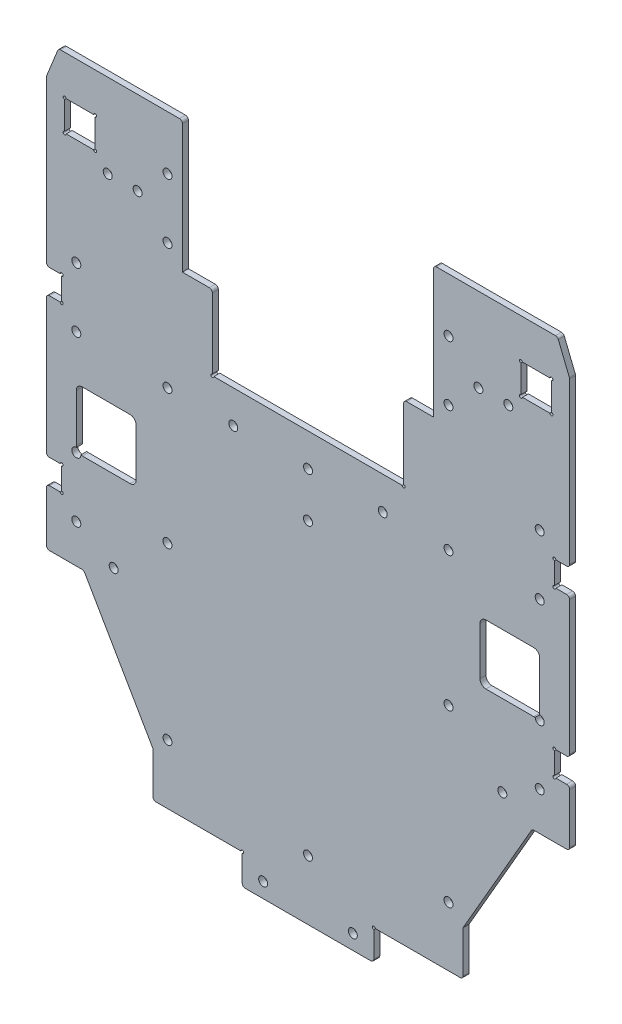
from build123d import *

# Parameters (mm, degrees)
SKETCH_1_R          = 1.5
SKETCH_1_W          = 10.2
SKETCH_1_H          = 10.2
EXTRUDE_3_DEPTH     = 2
SKETCH_3_R          = 1.5
SKETCH_3_W          = 5.1
SKETCH_3_H          = 8.2
CUT_EXTRUDE_2_DEPTH = 3
SKETCH_4_W          = 10
SKETCH_4_H          = 25
EXTRUDE_4_DEPTH     = 2
SKETCH_2_R          = 0.5
CUT_EXTRUDE_1_DEPTH = 3
FILLET_1_R          = 1
CUT_EXTRUDE_3_DEPTH = 10
SKETCH_6_R          = 1.5
CUT_EXTRUDE_4_DEPTH = 10


with BuildPart() as part:
    # 草图1 → 凸台-拉伸3 (new body)
    with BuildSketch(Plane.XY):
        Polygon((-87.5, 69), (-87.5, -77.9), (-74.994010768, -77.9), (-51.9, -117.9), (-51.9, -132.9), (-22, -132.9), (-22, -143), (22, -143), (22, -132.9), (51.9, -132.9), (51.9, -117.9), (74.994010768, -77.9), (87.5, -77.9), (87.5, 69), (42, 69), (42, 0), (-42, 0), (-42, 69), align=None)
        with Locations((-25, -11)):
            Circle(SKETCH_1_R, mode=Mode.SUBTRACT)
        with Locations((0, -26)):
            Circle(SKETCH_1_R, mode=Mode.SUBTRACT)
        with Locations((-47, -11)):
            Circle(SKETCH_1_R, mode=Mode.SUBTRACT)
        with Locations((-15, -138)):
            Circle(SKETCH_1_R, mode=Mode.SUBTRACT)
        with Locations((0, -123)):
            Circle(SKETCH_1_R, mode=Mode.SUBTRACT)
        with Locations((47, -11)):
            Circle(SKETCH_1_R, mode=Mode.SUBTRACT)
        with Locations((25, -11)):
            Circle(SKETCH_1_R, mode=Mode.SUBTRACT)
        with Locations((15, -138)):
            Circle(SKETCH_1_R, mode=Mode.SUBTRACT)
        with Locations((0, -11)):
            Circle(SKETCH_1_R, mode=Mode.SUBTRACT)
        with Locations((-47, 51)):
            Circle(SKETCH_1_R, mode=Mode.SUBTRACT)
        with Locations((47, 51)):
            Circle(SKETCH_1_R, mode=Mode.SUBTRACT)
        with Locations((-47, -113)):
            Circle(SKETCH_1_R, mode=Mode.SUBTRACT)
        with Locations((-47, -56)):
            Circle(SKETCH_1_R, mode=Mode.SUBTRACT)
        with Locations((47, -56)):
            Circle(SKETCH_1_R, mode=Mode.SUBTRACT)
        with Locations((47, -113)):
            Circle(SKETCH_1_R, mode=Mode.SUBTRACT)
        with Locations((-47, 31)):
            Circle(SKETCH_1_R, mode=Mode.SUBTRACT)
        with Locations((-67, 41)):
            Circle(SKETCH_1_R, mode=Mode.SUBTRACT)
        with Locations((-57, 41)):
            Circle(SKETCH_1_R, mode=Mode.SUBTRACT)
        with Locations((57, 41)):
            Circle(SKETCH_1_R, mode=Mode.SUBTRACT)
        with Locations((67, 41)):
            Circle(SKETCH_1_R, mode=Mode.SUBTRACT)
        with Locations((47, 31)):
            Circle(SKETCH_1_R, mode=Mode.SUBTRACT)
        with Locations((76.3, 50.7)):
            Rectangle(SKETCH_1_W, SKETCH_1_H, mode=Mode.SUBTRACT)
        with Locations((-76.3, 50.7)):
            Rectangle(SKETCH_1_W, SKETCH_1_H, mode=Mode.SUBTRACT)
    extrude(amount=EXTRUDE_3_DEPTH)

    # 草图3 → 切除-拉伸2 (cut, through all)
    with BuildSketch(Plane.XY.offset(2)):
        with Locations((77.5, 10)):
            Circle(SKETCH_3_R)
        with Locations((77.5, -10)):
            Circle(SKETCH_3_R)
        with Locations((77.5, -45)):
            Circle(SKETCH_3_R)
        with Locations((77.5, -65)):
            Circle(SKETCH_3_R)
        with Locations((-77.5, -45)):
            Circle(SKETCH_3_R)
        with Locations((-77.5, -65)):
            Circle(SKETCH_3_R)
        with Locations((-77.5, -10)):
            Circle(SKETCH_3_R)
        with Locations((-77.5, 10)):
            Circle(SKETCH_3_R)
        with Locations((84.95, 0)):
            Rectangle(SKETCH_3_W, SKETCH_3_H)
        with Locations((-84.95, 0)):
            Rectangle(SKETCH_3_W, SKETCH_3_H)
        with Locations((-84.95, -55)):
            Rectangle(SKETCH_3_W, SKETCH_3_H)
        with Locations((84.95, -55)):
            Rectangle(SKETCH_3_W, SKETCH_3_H)
        Polygon((83.459737742, 69), (87.5, 59), (87.5, 69), align=None)
        Polygon((-87.5, 59), (-87.5, 69), (-83.459737742, 69), align=None)
    extrude(amount=-CUT_EXTRUDE_2_DEPTH, mode=Mode.SUBTRACT)

    # 草图4 → 凸台-拉伸4 (add)
    with BuildSketch(Plane(origin=(0, 0, 0), x_dir=(-1, 0, 0), z_dir=(0, 0, -1))):
        with Locations((-37, 12.5)):
            Rectangle(SKETCH_4_W, SKETCH_4_H)
        with Locations((37, 12.5)):
            Rectangle(SKETCH_4_W, SKETCH_4_H)
    extrude(amount=-EXTRUDE_4_DEPTH)

    # 草图2 → 切除-拉伸1 (cut, through all)
    with BuildSketch(Plane.XY.offset(2)):
        with Locations((-81.4, 45.6)):
            Circle(SKETCH_2_R)
        with Locations((-81.4, 55.8)):
            Circle(SKETCH_2_R)
        with Locations((-71.2, 45.6)):
            Circle(SKETCH_2_R)
        with Locations((-71.2, 55.8)):
            Circle(SKETCH_2_R)
        with Locations((71.2, 55.8)):
            Circle(SKETCH_2_R)
        with Locations((71.2, 45.6)):
            Circle(SKETCH_2_R)
        with Locations((81.4, 55.8)):
            Circle(SKETCH_2_R)
        with Locations((81.4, 45.6)):
            Circle(SKETCH_2_R)
        with Locations((82.4, 4.1)):
            Circle(SKETCH_2_R)
        with Locations((82.4, -4.1)):
            Circle(SKETCH_2_R)
        with Locations((82.4, -50.9)):
            Circle(SKETCH_2_R)
        with Locations((82.4, -59.1)):
            Circle(SKETCH_2_R)
        with Locations((22, -132.9)):
            Circle(SKETCH_2_R)
        with Locations((-82.4, -59.1)):
            Circle(SKETCH_2_R)
        with Locations((-82.4, -50.9)):
            Circle(SKETCH_2_R)
        with Locations((-82.4, -4.1)):
            Circle(SKETCH_2_R)
        with Locations((-82.4, 4.1)):
            Circle(SKETCH_2_R)
        with Locations((-22, -132.9)):
            Circle(SKETCH_2_R)
        with Locations((32, 0)):
            Circle(SKETCH_2_R)
        with Locations((-32, 0)):
            Circle(SKETCH_2_R)
    extrude(amount=-CUT_EXTRUDE_1_DEPTH, mode=Mode.SUBTRACT)

    # 圆角1
    fillet_1_edges = [part.edges().sort_by_distance(p)[0] for p in [
        (87.5, -50.9, 1),
        (87.5, -59.1, 1),
        (-87.5, -59.1, 1),
        (-87.5, -50.9, 1),
        (-87.5, -4.1, 1),
        (-87.5, 4.1, 1),
        (83.459737742, 69, 1),
        (87.5, 59, 1),
        (-83.459737742, 69, 1),
        (-87.5, 59, 1),
        (87.5, 4.1, 1),
        (87.5, -4.1, 1),
        (32, 25, 1),
        (-32, 25, 1),
        (-87.5, -77.9, 1),
        (-42, 69, 1),
        (42, 69, 1),
        (87.5, -77.9, 1),
        (74.994010768, -77.9, 1),
        (51.9, -132.9, 1),
        (22, -143, 1),
        (-22, -143, 1),
        (-51.9, -132.9, 1),
        (-74.994010768, -77.9, 1),
    ]]
    fillet(fillet_1_edges, radius=FILLET_1_R)

    # 草图5 → 切除-拉伸3 (cut)
    with BuildSketch(Plane.XY.offset(2)):
        with BuildLine():
            Line((-75.5, -25), (-59.5, -25))
            ThreePointArc((-59.5, -25), (-58.085786438, -25.585786438), (-57.5, -27))
            Line((-57.5, -27), (-57.5, -43))
            ThreePointArc((-57.5, -43), (-58.085786438, -44.414213562), (-59.5, -45))
            Line((-59.5, -45), (-75.5, -45))
            ThreePointArc((-75.5, -45), (-76.914213562, -44.414213562), (-77.5, -43))
            Line((-77.5, -43), (-77.5, -27))
            ThreePointArc((-77.5, -27), (-76.914213562, -25.585786438), (-75.5, -25))
        make_face()
        with BuildLine():
            Line((75.5, -45), (59.5, -45))
            ThreePointArc((59.5, -45), (58.085786438, -44.414213562), (57.5, -43))
            Line((57.5, -43), (57.5, -27))
            ThreePointArc((57.5, -27), (58.085786438, -25.585786438), (59.5, -25))
            Line((59.5, -25), (75.5, -25))
            ThreePointArc((75.5, -25), (76.914213562, -25.585786438), (77.5, -27))
            Line((77.5, -27), (77.5, -43))
            ThreePointArc((77.5, -43), (76.914213562, -44.414213562), (75.5, -45))
        make_face()
    extrude(amount=-CUT_EXTRUDE_3_DEPTH, mode=Mode.SUBTRACT)

    # 草图6 → 切除-拉伸4 (cut)
    with BuildSketch(Plane.XY.offset(2)):
        with Locations((-65, -72.2)):
            Circle(SKETCH_6_R)
        with Locations((65, -72.2)):
            Circle(SKETCH_6_R)
    extrude(amount=-CUT_EXTRUDE_4_DEPTH, mode=Mode.SUBTRACT)


solid = part.part
